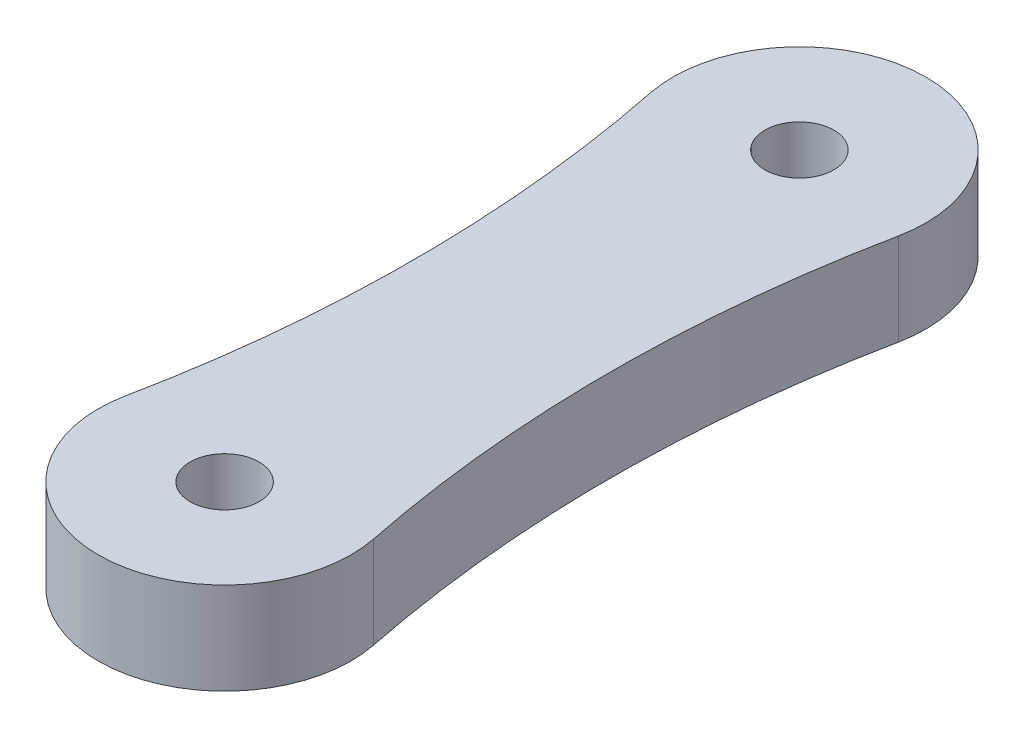
from build123d import *

# Parameters (mm, degrees)
SKETCH1_R           = 1.5
BOSS_EXTRUDE1_DEPTH = 4


with BuildPart() as part:
    # Sketch1 → Boss-Extrude1 (new body)
    with BuildSketch(Plane(origin=(0, 0, 0), x_dir=(1, 0, 0), z_dir=(0, 1, 0))):
        with BuildLine():
            ThreePointArc((-5.391089109, 1.089108911), (0, -5.5), (5.391089109, 1.089108911))
            ThreePointArc((5.391089109, 1.089108911), (4.25, 12.5), (5.391089109, 23.910891089))
            ThreePointArc((5.391089109, 23.910891089), (0, 30.5), (-5.391089109, 23.910891089))
            ThreePointArc((-5.391089109, 23.910891089), (-4.25, 12.5), (-5.391089109, 1.089108911))
        make_face()
        Circle(SKETCH1_R, mode=Mode.SUBTRACT)
        with Locations((0, 25)):
            Circle(SKETCH1_R, mode=Mode.SUBTRACT)
    extrude(amount=BOSS_EXTRUDE1_DEPTH)


solid = part.part
